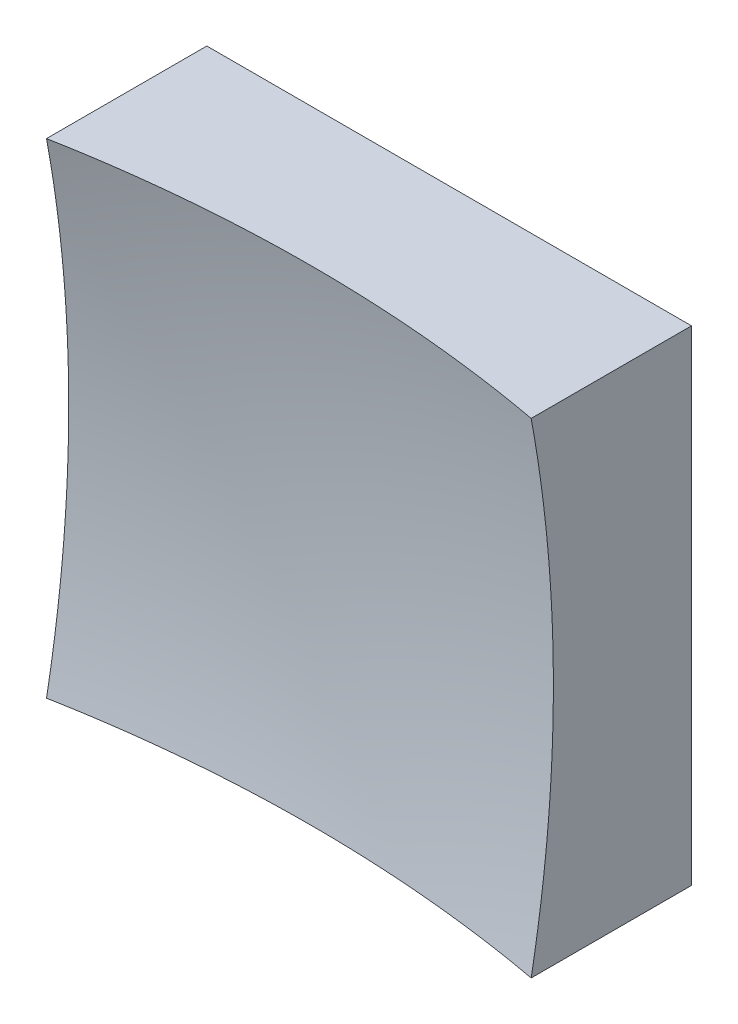
from build123d import *

# Parameters (mm, degrees)
SKETCH_1_W      = 25
SKETCH_1_H      = 25
EXTRUDE_1_DEPTH = 20


with BuildPart() as part:
    # 草图1 → 凸台-拉伸1 (new body)
    with BuildSketch(Plane.XY):
        Rectangle(SKETCH_1_W, SKETCH_1_H)
    extrude(amount=EXTRUDE_1_DEPTH)

    # 草图2 → 切除-旋转2 (revolve, cut)
    with BuildSketch(Plane(origin=(0, 0, 0), x_dir=(1, 0, 0), z_dir=(0, 1, 0))):
        with BuildLine():
            Line((68.239182327, -60.398269476), (0, -60.398269476))
            Line((0, -60.398269476), (0, -6))
            ThreePointArc((0, -6), (43.634154417, -21.263717989), (68.239182327, -60.398269476))
        make_face()
    revolve(axis=Axis((0, 0, 60.398269476), (0, 0, -1)), mode=Mode.SUBTRACT)


solid = part.part
